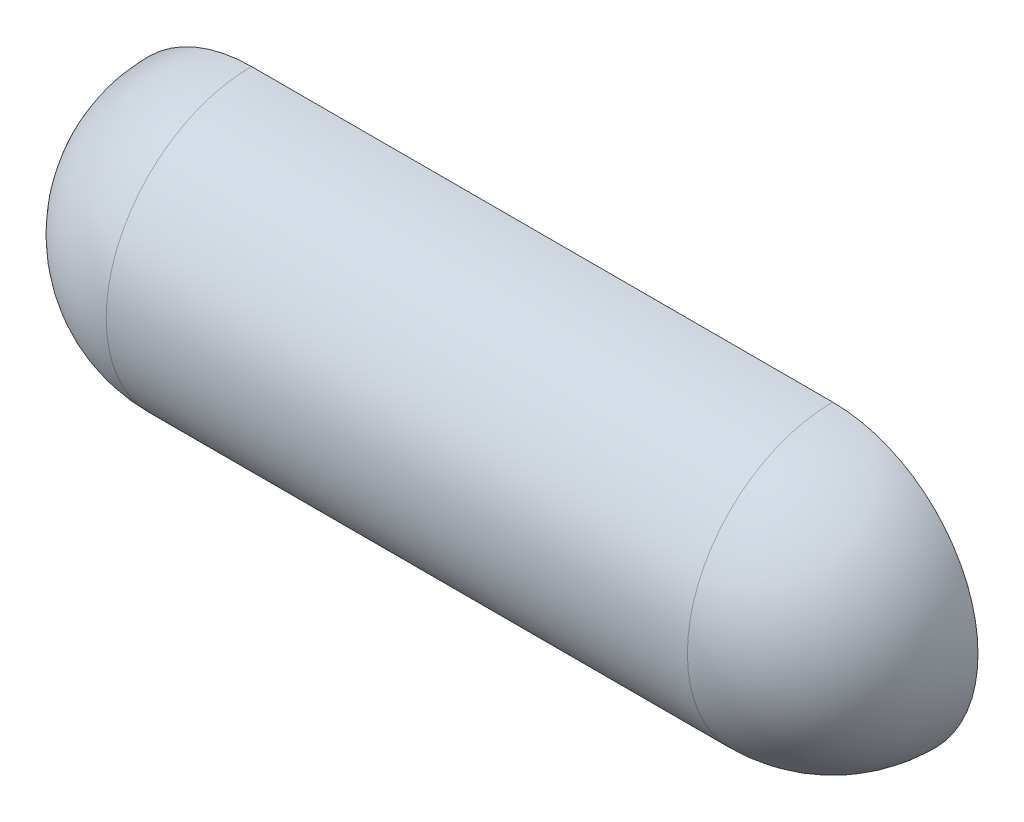
from build123d import *

# Parameters (mm, degrees)
REVOLVE1_ANGLE = 180


with BuildPart() as part:
    # Sketch1 → Revolve1 (revolve)
    with BuildSketch(Plane.XY):
        with BuildLine():
            Line((-75, 0), (375, 0))
            ThreePointArc((375, 0), (353.033008589, 53.033008589), (300, 75))
            Line((300, 75), (0, 75))
            ThreePointArc((0, 75), (-53.033008589, 53.033008589), (-75, 0))
        make_face()
    revolve(axis=Axis((-75, 0, 0), (1, 0, 0)), revolution_arc=REVOLVE1_ANGLE)


solid = part.part
